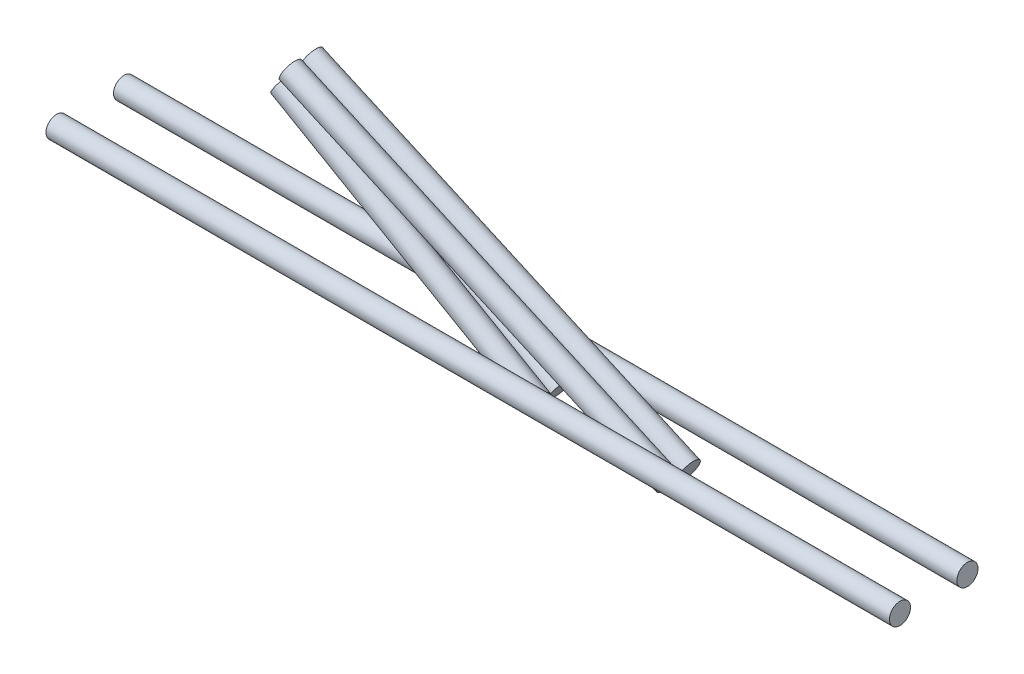
from build123d import *

# Parameters (mm, degrees)
SKETCH_2_R             = 2.5
EXTRUDE_1_DEPTH        = 100
EXTRUDE_1_DEPTH_BACK   = 100
SKETCH_3_R             = 2.5
EXTRUDE_START          = 100
SKETCH_5_R             = 2.5
EXTRUDE_3_DEPTH        = 100
EXTRUDE_4_DEPTH        = 60
EXTRUDE_4_DEPTH_BACK   = 10
SKETCH_9_R             = 2.5
EXTRUDE_4_2_DEPTH      = 60
EXTRUDE_4_2_DEPTH_BACK = 10
EXTRUDE_5_DEPTH        = 15
EXTRUDE_5_DEPTH_BACK   = 83
SKETCH_12_R            = 2.5


with BuildPart() as part:
    # 扫描1: sweep along a path in 草图1
    with BuildLine(Plane(origin=(0, 0, 0), x_dir=(1, 0, 0), z_dir=(0, 1, 0))) as sweep_1_path:
        Line((70.676444451, 8), (170.676444451, 8))
    # 草图2 → 扫描1 (sweep)
    with BuildSketch(Plane(origin=(170.676444451, 0, -8), x_dir=(0, 0, -1), z_dir=(1, 0, 0))):
        with Locations((-0.391587181, 0)):
            Circle(SKETCH_2_R)
    sweep(path=sweep_1_path.line)

    # 草图5 → 凸台-拉伸3 (add)
    with BuildSketch(Plane(origin=(170.676444451, 0, 0), x_dir=(0, 0, -1), z_dir=(1, 0, 0)).offset(EXTRUDE_START)):
        with Locations((7.608412819, 0)):
            Circle(SKETCH_5_R)
    extrude(amount=-EXTRUDE_3_DEPTH)


with BuildPart() as body_2:
    # 草图3 → 凸台-拉伸1 (new, two sides: drawn at the far end of the back side and taken through both)
    with BuildSketch(Plane(origin=(170.676444451, 0, 0), x_dir=(0, 0, -1), z_dir=(1, 0, 0)).offset(-EXTRUDE_1_DEPTH_BACK)):
        with Locations((-8.391587181, 0)):
            Circle(SKETCH_3_R)
    extrude(amount=EXTRUDE_1_DEPTH + EXTRUDE_1_DEPTH_BACK)


with BuildPart() as body_3:
    # 草图9 → 凸台-拉伸4 (new, two sides: drawn at the far end of the back side and taken through both)
    with BuildSketch(Plane(origin=(128.007333338, -73.905068361, 0), x_dir=(0, 0, -1), z_dir=(-0.8660254037844416, 0.49999999999999495, 0)).offset(-EXTRUDE_4_DEPTH_BACK)):
        with Locations((2.18412613, -85.289583238)):
            Circle(SKETCH_9_R)
    extrude(amount=EXTRUDE_4_DEPTH + EXTRUDE_4_DEPTH_BACK)



with BuildPart() as body_4:
    # 草图9 → Extrude 4 2 (new, two sides: drawn at the far end of the back side and taken through both)
    with BuildSketch(Plane(origin=(128.007333338, -73.905068361, 0), x_dir=(0, 0, -1), z_dir=(-0.8660254037844416, 0.49999999999999495, 0)).offset(-EXTRUDE_4_2_DEPTH_BACK)):
        with Locations((-2.81587387, -85.289583238)):
            Circle(SKETCH_9_R)
    extrude(amount=EXTRUDE_4_2_DEPTH + EXTRUDE_4_2_DEPTH_BACK)


with BuildPart() as body_3_1:
    add(body_3.part)

    add(body_4.part)  # 凸台-拉伸5 merges body 4
    # 草图12 → 凸台-拉伸5 (add, two sides: drawn at the far end of the back side and taken through both)
    with BuildSketch(Plane(origin=(196.426899862, 0, 0), x_dir=(0, 0, -1), z_dir=(0.9131044962608523, -0.40772561718417333, 0)).offset(-EXTRUDE_5_DEPTH_BACK)):
        with Locations((2.108412819, 0.054468103)):
            Circle(SKETCH_12_R)
        with Locations((-2.891587181, 0.054468103)):
            Circle(SKETCH_12_R)
    extrude(amount=EXTRUDE_5_DEPTH + EXTRUDE_5_DEPTH_BACK)


solid = Compound([part.part, body_2.part, body_3_1.part])
